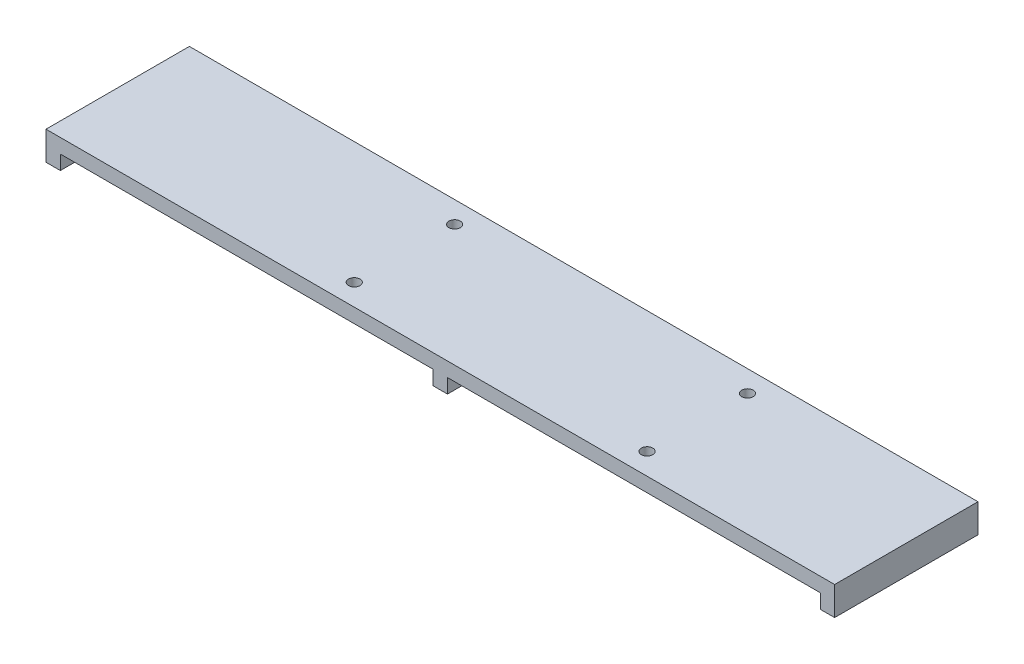
from build123d import *

# Parameters (mm, degrees)
SCHIZZO1_W                   = 550
SCHIZZO1_H                   = 100
SCHIZZO1_R                   = 4
ESTRUSIONE_ESTRUSIONE1_DEPTH = 10
SCHIZZO2_W                   = 10
SCHIZZO2_H                   = 100
ESTRUSIONE_ESTRUSIONE2_DEPTH = 10


with BuildPart() as part:
    # Schizzo1 → Estrusione-Estrusione1 (new body)
    with BuildSketch(Plane(origin=(0, 0, 0), x_dir=(1, 0, 0), z_dir=(0, 1, 0))):
        with Locations((275, 50)):
            Rectangle(SCHIZZO1_W, SCHIZZO1_H)
        with Locations((200, 85)):
            Circle(SCHIZZO1_R, mode=Mode.SUBTRACT)
        with Locations((200, 15)):
            Circle(SCHIZZO1_R, mode=Mode.SUBTRACT)
        with Locations((404.2, 15)):
            Circle(SCHIZZO1_R, mode=Mode.SUBTRACT)
        with Locations((404.2, 85)):
            Circle(SCHIZZO1_R, mode=Mode.SUBTRACT)
    extrude(amount=ESTRUSIONE_ESTRUSIONE1_DEPTH)

    # Schizzo2 → Estrusione-Estrusione2 (add)
    with BuildSketch(Plane.XZ):
        with Locations((5, -50)):
            Rectangle(SCHIZZO2_W, SCHIZZO2_H)
        with Locations((545, -50)):
            Rectangle(SCHIZZO2_W, SCHIZZO2_H)
        with Locations((275, -50)):
            Rectangle(SCHIZZO2_W, SCHIZZO2_H)
    extrude(amount=ESTRUSIONE_ESTRUSIONE2_DEPTH)


solid = part.part
